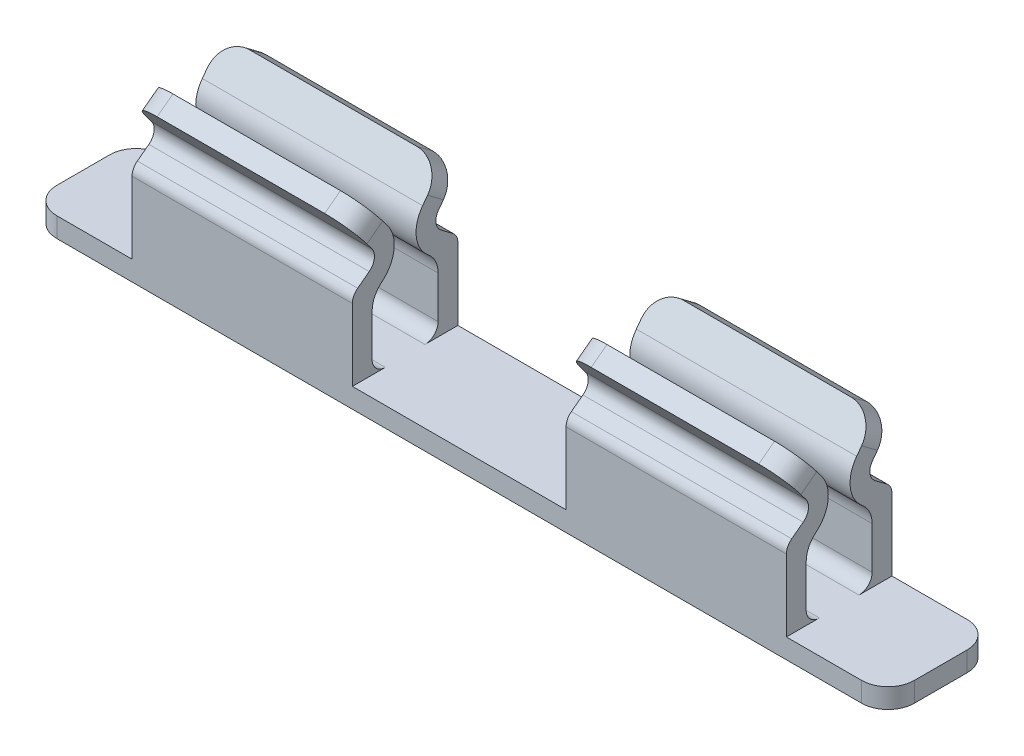
from build123d import *

# Parameters (mm, degrees)
EXTRUDE_1_DEPTH          = 3.25
SKETCH_2_W               = 1.62
SKETCH_2_H               = 1.13
SKETCH_2_W_2             = 0.77
CUT_EXTRUDE_1_DEPTH      = 1.41
CUT_EXTRUDE_1_DEPTH_BACK = 1.41
FILLET_1_R               = 0.2


with BuildPart() as part:
    # Эскиз1 → Бобышка-Вытянуть1 (new body, symmetric)
    with BuildSketch(Plane(origin=(0, 0, 0), x_dir=(0, 0, -1), z_dir=(1, 0, 0))):
        with BuildLine():
            Line((-0.4, 0), (0.4, 0))
            Line((0.4, 0), (0.4, 0.694375))
            ThreePointArc((0.4, 0.694375), (0.389442719, 0.73909636), (0.36, 0.774375))
            Line((0.36, 0.774375), (0.2725, 0.84))
            ThreePointArc((0.2725, 0.84), (0.233505051, 0.905857864), (0.2525, 0.98))
            Line((0.2525, 0.98), (0.41, 1.19))
            Line((0.41, 1.19), (0.29, 1.28))
            Line((0.29, 1.28), (0.1325, 1.07))
            ThreePointArc((0.1325, 1.07), (0.085012627, 0.884644661), (0.1825, 0.72))
            Line((0.1825, 0.72), (0.17, 0.729375))
            ThreePointArc((0.17, 0.729375), (0.228885438, 0.658817719), (0.25, 0.569375))
            Line((0.25, 0.569375), (0.25, 0.25))
            ThreePointArc((0.25, 0.25), (0.220710678, 0.179289322), (0.15, 0.15))
            Line((0.15, 0.15), (-0.15, 0.15))
            ThreePointArc((-0.15, 0.15), (-0.220710678, 0.179289322), (-0.25, 0.25))
            Line((-0.25, 0.25), (-0.25, 0.569375))
            ThreePointArc((-0.25, 0.569375), (-0.228885438, 0.658817719), (-0.17, 0.729375))
            Line((-0.17, 0.729375), (-0.1825, 0.72))
            ThreePointArc((-0.1825, 0.72), (-0.085012627, 0.884644661), (-0.1325, 1.07))
            Line((-0.1325, 1.07), (-0.29, 1.28))
            Line((-0.29, 1.28), (-0.41, 1.19))
            Line((-0.41, 1.19), (-0.2525, 0.98))
            ThreePointArc((-0.2525, 0.98), (-0.233505051, 0.905857864), (-0.2725, 0.84))
            Line((-0.2725, 0.84), (-0.36, 0.774375))
            ThreePointArc((-0.36, 0.774375), (-0.389442719, 0.73909636), (-0.4, 0.694375))
            Line((-0.4, 0.694375), (-0.4, 0))
        make_face()
    extrude(amount=EXTRUDE_1_DEPTH, both=True)

    # Эскиз2 → Вырез-Вытянуть1 (cut, two sides)
    with BuildSketch(Plane.XY) as cut_extrude_1_sk:
        with Locations((0, 0.715)):
            Rectangle(SKETCH_2_W, SKETCH_2_H)
        with Locations((-2.865, 0.715)):
            Rectangle(SKETCH_2_W_2, SKETCH_2_H)
        with Locations((2.865, 0.715)):
            Rectangle(SKETCH_2_W_2, SKETCH_2_H)
    extrude(amount=CUT_EXTRUDE_1_DEPTH, mode=Mode.SUBTRACT)
    extrude(cut_extrude_1_sk.sketch, amount=-CUT_EXTRUDE_1_DEPTH_BACK, mode=Mode.SUBTRACT)

    # Скругление1
    fillet_1_edges = [part.edges().sort_by_distance(p)[0] for p in [
        (2.48, 1.235, -0.35),
        (2.48, 1.235, 0.35),
        (-2.48, 1.235, -0.35),
        (-2.48, 1.235, 0.35),
        (-0.81, 1.235, -0.35),
        (-0.81, 1.235, 0.35),
        (0.81, 1.235, -0.35),
        (0.81, 1.235, 0.35),
        (-3.25, 0.075, -0.4),
        (3.25, 0.075, -0.4),
        (-3.25, 0.075, 0.4),
        (3.25, 0.075, 0.4),
    ]]
    fillet(fillet_1_edges, radius=FILLET_1_R)


solid = part.part
